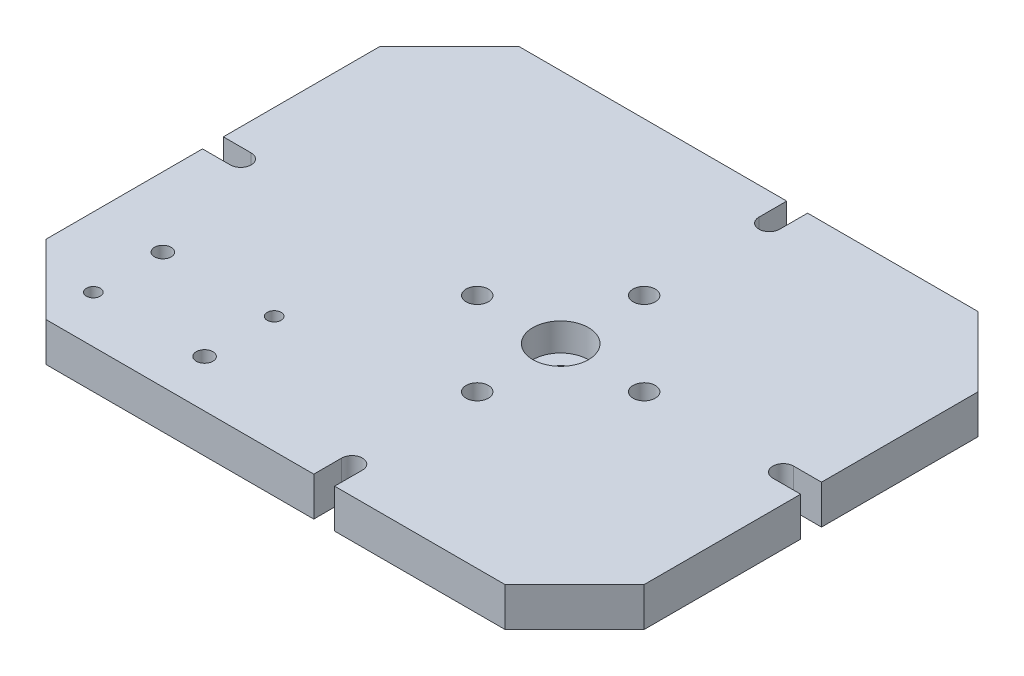
from build123d import *

# Parameters (mm, degrees)
EXTRUDE_1_DEPTH     = 28
SKETCH_2_R          = 8
CUT_EXTRUDE_1_DEPTH = 28
SKETCH_3_R          = 6
SKETCH_3_R_2        = 5
CUT_EXTRUDE_2_DEPTH = 28
SKETCH_4_R          = 20
CUT_EXTRUDE_3_DEPTH = 20
SKETCH_5_R          = 9
CUT_EXTRUDE_4_DEPTH = 20


with BuildPart() as part:
    # Эскиз1 → Бобышка-Вытянуть1 (new body)
    with BuildSketch(Plane(origin=(0, 0, 0), x_dir=(1, 0, 0), z_dir=(0, 1, 0))):
        with BuildLine():
            Line((0, 50), (50, 0))
            Line((50, 0), (242.5, 0))
            Line((242.5, 0), (242.5, 20))
            ThreePointArc((242.5, 20), (250, 27.5), (257.5, 20))
            Line((257.5, 20), (257.5, 0))
            Line((257.5, 0), (380, 0))
            Line((380, 0), (430, 50))
            Line((430, 50), (430, 162.5))
            Line((430, 162.5), (410, 162.5))
            ThreePointArc((410, 162.5), (402.5, 170), (410, 177.5))
            Line((410, 177.5), (430, 177.5))
            Line((430, 177.5), (430, 290))
            Line((430, 290), (380, 340))
            Line((380, 340), (257.5, 340))
            Line((257.5, 340), (257.5, 320))
            ThreePointArc((257.5, 320), (250, 312.5), (242.5, 320))
            Line((242.5, 320), (242.5, 340))
            Line((242.5, 340), (50, 340))
            Line((50, 340), (0, 290))
            Line((0, 290), (0, 177.5))
            Line((0, 177.5), (20, 177.5))
            ThreePointArc((20, 177.5), (27.5, 170), (20, 162.5))
            Line((20, 162.5), (0, 162.5))
            Line((0, 162.5), (0, 50))
        make_face()
    extrude(amount=EXTRUDE_1_DEPTH)

    # Эскиз2 → Вырез-Вытянуть1 (cut)
    with BuildSketch(Plane(origin=(0, 28, 0), x_dir=(1, 0, 0), z_dir=(0, 1, 0))):
        with Locations((250, 230)):
            Circle(SKETCH_2_R)
        with Locations((190, 170)):
            Circle(SKETCH_2_R)
        with Locations((250, 110)):
            Circle(SKETCH_2_R)
        with Locations((310, 170)):
            Circle(SKETCH_2_R)
    extrude(amount=-CUT_EXTRUDE_1_DEPTH, mode=Mode.SUBTRACT)

    # Эскиз3 → Вырез-Вытянуть2 (cut)
    with BuildSketch(Plane(origin=(0, 28, 0), x_dir=(1, 0, 0), z_dir=(0, 1, 0))):
        with Locations((50, 84)):
            Circle(SKETCH_3_R)
        with Locations((130, 84)):
            Circle(SKETCH_3_R_2)
        with Locations((50, 34)):
            Circle(SKETCH_3_R_2)
        with Locations((130, 34)):
            Circle(SKETCH_3_R)
    extrude(amount=-CUT_EXTRUDE_2_DEPTH, mode=Mode.SUBTRACT)

    # Эскиз4 → Вырез-Вытянуть3 (cut)
    with BuildSketch(Plane(origin=(0, 28, 0), x_dir=(1, 0, 0), z_dir=(0, 1, 0))):
        with Locations((250, 170)):
            Circle(SKETCH_4_R)
    extrude(amount=-CUT_EXTRUDE_3_DEPTH, mode=Mode.SUBTRACT)

    # Эскиз5 → Вырез-Вытянуть4 (cut)
    with BuildSketch(Plane(origin=(0, 8, 0), x_dir=(1, 0, 0), z_dir=(0, 1, 0))):
        with Locations((250, 170)):
            Circle(SKETCH_5_R)
    extrude(amount=-CUT_EXTRUDE_4_DEPTH, mode=Mode.SUBTRACT)


solid = part.part
